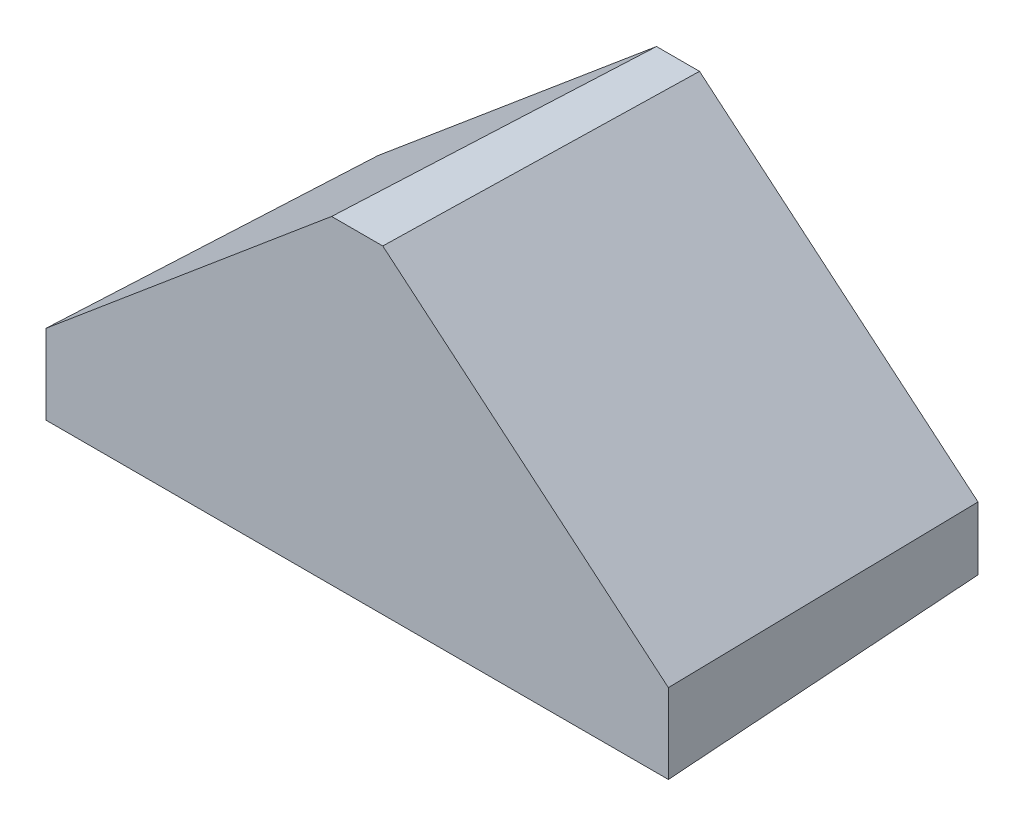
from build123d import *

# Parameters (mm, degrees)
SALIENTE_EXTRUIR3_DEPTH = 50.8
SALIENTE_EXTRUIR3_TAPER = -2


with BuildPart() as part:
    # Croquis6 → Saliente-Extruir3 (new body)
    with BuildSketch(Plane.XY):
        Polygon((0, 0), (95, 0), (95, 10), (50.905117074, 47), (44.094882926, 47), (0, 10), align=None)
    extrude(amount=SALIENTE_EXTRUIR3_DEPTH, taper=SALIENTE_EXTRUIR3_TAPER)


solid = part.part
